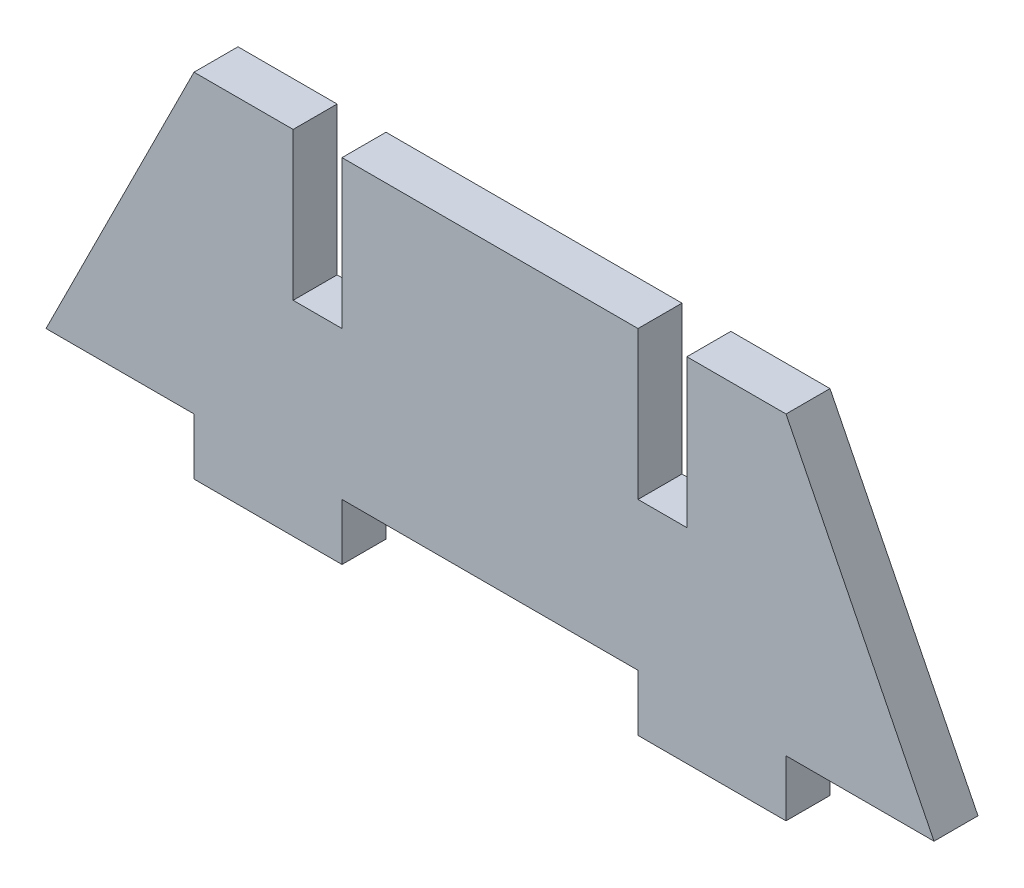
from build123d import *

# Parameters (mm, degrees)
SKETCH1_W           = 40
SKETCH1_H           = 20
BOSS_EXTRUDE1_DEPTH = 2.9718
BOSS_EXTRUDE2_DEPTH = 2.9718
SKETCH3_W           = 3.302
SKETCH3_H           = 20
CUT_EXTRUDE1_DEPTH  = 3.9718
SKETCH4_W           = 10
SKETCH4_H           = 3.81
BOSS_EXTRUDE3_DEPTH = 2.9718


with BuildPart() as part:
    # Sketch1 → Boss-Extrude1 (new body)
    with BuildSketch(Plane.XY):
        Rectangle(SKETCH1_W, SKETCH1_H)
    extrude(amount=BOSS_EXTRUDE1_DEPTH)

    # Sketch2 → Boss-Extrude2 (add)
    with BuildSketch(Plane.XY.offset(2.9718)):
        Polygon((-20, 10), (-30, -10), (-20, -10), align=None)
        Polygon((20, -10), (20, 10), (30, -10), align=None)
    extrude(amount=-BOSS_EXTRUDE2_DEPTH)

    # Sketch3 → Cut-Extrude1 (cut, through all)
    with BuildSketch(Plane.XY.offset(2.9718)):
        with Locations((-11.651, 10)):
            Rectangle(SKETCH3_W, SKETCH3_H)
        with Locations((11.651, 10)):
            Rectangle(SKETCH3_W, SKETCH3_H)
    extrude(amount=-CUT_EXTRUDE1_DEPTH, mode=Mode.SUBTRACT)

    # Sketch4 → Boss-Extrude3 (add)
    with BuildSketch(Plane.XY.offset(2.9718)):
        with Locations((-15, -11.905)):
            Rectangle(SKETCH4_W, SKETCH4_H)
        with Locations((15, -11.905)):
            Rectangle(SKETCH4_W, SKETCH4_H)
    extrude(amount=-BOSS_EXTRUDE3_DEPTH)


solid = part.part
